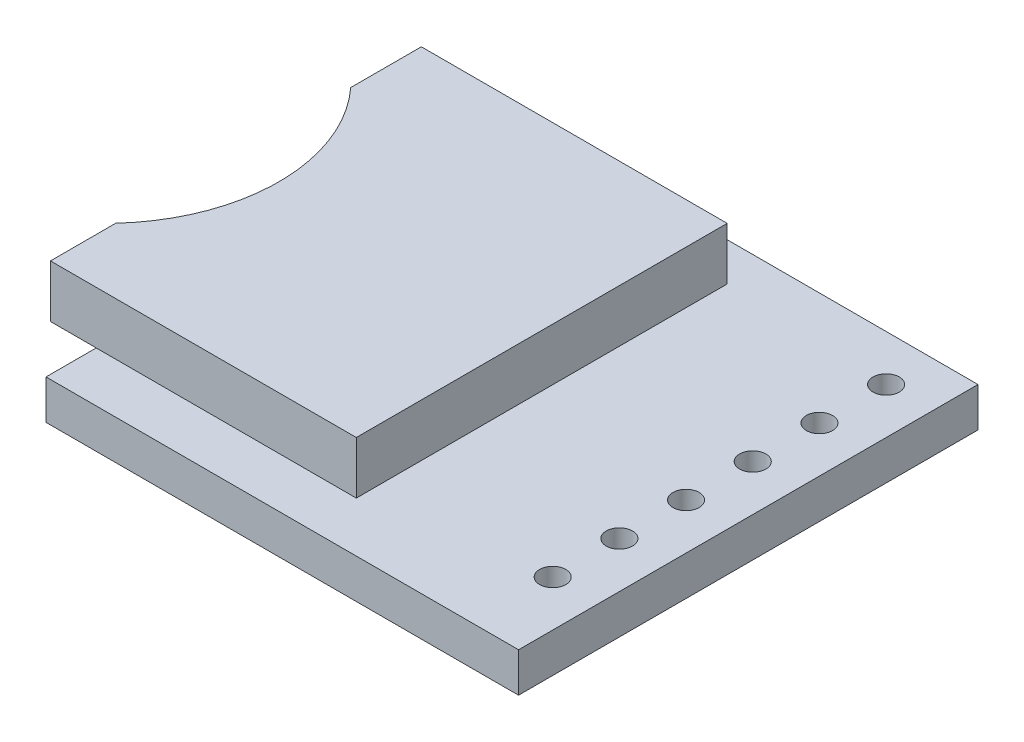
from build123d import *

# Parameters (mm, degrees)
SKETCH1_W           = 18
SKETCH1_H           = 17.5
BOSS_EXTRUDE1_DEPTH = 1.5
BOSS_EXTRUDE2_DEPTH = 2
SKETCH3_R           = 0.5
CUT_EXTRUDE1_DEPTH  = 2.5
SKETCH4_W           = 11.451958773
SKETCH4_H           = 0.968573627
CUT_EXTRUDE2_DEPTH  = 9.649638


with BuildPart() as part:
    # Sketch1 → Boss-Extrude1 (new body)
    with BuildSketch(Plane(origin=(0, 0, 0), x_dir=(1, 0, 0), z_dir=(0, 1, 0))):
        with Locations((9, 8.75)):
            Rectangle(SKETCH1_W, SKETCH1_H)
    extrude(amount=BOSS_EXTRUDE1_DEPTH)

    # Sketch2 → Boss-Extrude2 (add)
    with BuildSketch(Plane(origin=(0, 1.5, 0), x_dir=(1, 0, 0), z_dir=(0, 1, 0))):
        with BuildLine():
            Line((-1.742375604, 4.397064227), (-1.742375604, 1.912224032))
            Line((-1.742375604, 1.912224032), (9.907262148, 1.912224032))
            Line((9.907262148, 1.912224032), (9.907262148, 16.039286602))
            Line((9.907262148, 16.039286602), (-1.742375604, 16.039286602))
            Line((-1.742375604, 16.039286602), (-1.742375604, 13.34923012))
            ThreePointArc((-1.742375604, 13.34923012), (0, 8.873147173), (-1.742375604, 4.397064227))
        make_face()
    extrude(amount=BOSS_EXTRUDE2_DEPTH)

    # Sketch3 → Cut-Extrude1 (cut, through all)
    with BuildSketch(Plane(origin=(0, 1.5, 0), x_dir=(1, 0, 0), z_dir=(0, 1, 0))):
        with Locations((16.25, 15.75)):
            Circle(SKETCH3_R)
        with Locations((16.25, 13.21)):
            Circle(SKETCH3_R)
        with Locations((16.25, 10.67)):
            Circle(SKETCH3_R)
        with Locations((16.25, 8.13)):
            Circle(SKETCH3_R)
        with Locations((16.25, 5.59)):
            Circle(SKETCH3_R)
        with Locations((16.25, 3.05)):
            Circle(SKETCH3_R)
    extrude(amount=-CUT_EXTRUDE1_DEPTH, mode=Mode.SUBTRACT)

    # Sketch4 → Cut-Extrude2 (cut)
    with BuildSketch(Plane.ZY.offset(1.742375604)):
        with Locations((-8.77848746, 2.504917681)):
            Rectangle(SKETCH4_W, SKETCH4_H)
    extrude(amount=-CUT_EXTRUDE2_DEPTH, mode=Mode.SUBTRACT)


solid = part.part
